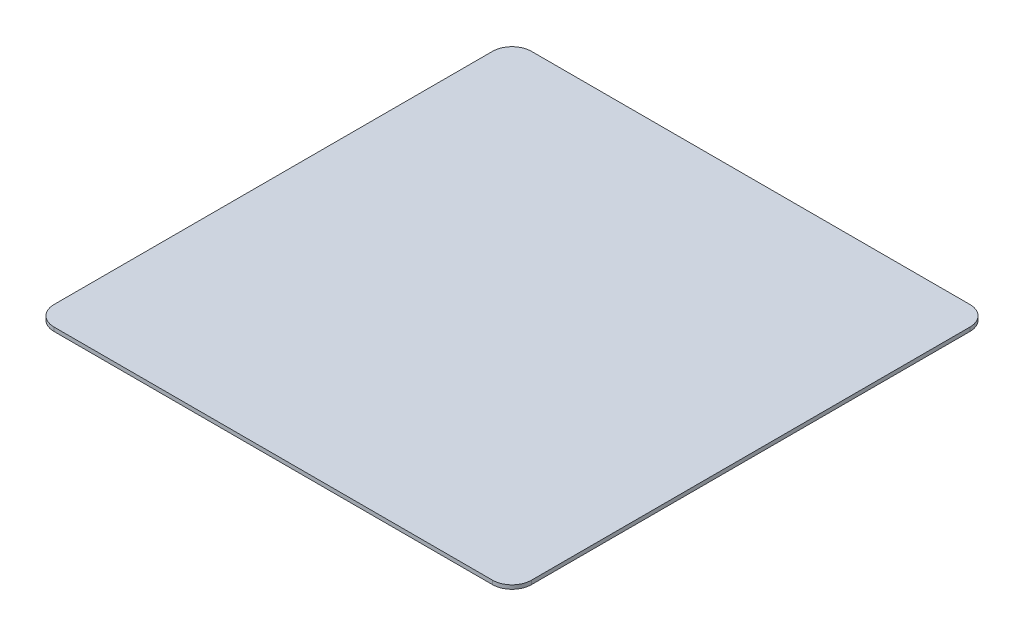
from build123d import *

# Parameters (mm, degrees)
SKETCH_1_W      = 245
SKETCH_1_H      = 245
EXTRUDE_1_DEPTH = 2
FILLET_1_R      = 10


with BuildPart() as part:
    # 草图1 → 凸台-拉伸1 (new body)
    with BuildSketch(Plane(origin=(0, 0, 0), x_dir=(1, 0, 0), z_dir=(0, 1, 0))):
        Rectangle(SKETCH_1_W, SKETCH_1_H)
    extrude(amount=EXTRUDE_1_DEPTH)

    # 圆角1
    fillet_1_edges = [part.edges().sort_by_distance(p)[0] for p in [
        (122.5, 1, 122.5),
        (-122.5, 1, 122.5),
        (-122.5, 1, -122.5),
        (122.5, 1, -122.5),
    ]]
    fillet(fillet_1_edges, radius=FILLET_1_R)


solid = part.part
